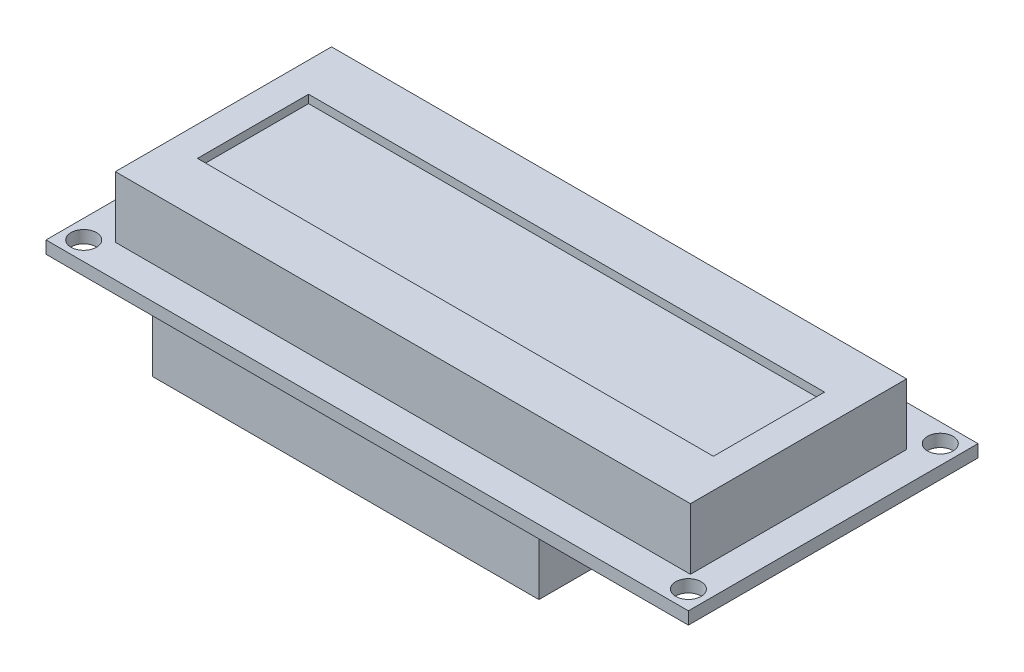
from build123d import *

# Parameters (mm, degrees)
SKETCH1_W           = 80.01
SKETCH1_H           = 36.068
SKETCH1_R           = 1.5875
PCB_DEPTH           = 1.5494
SKETCH2_W           = 71.628
SKETCH2_H           = 26.924
BOSS_EXTRUDE2_DEPTH = 7.62
SKETCH3_W           = 64.262
SKETCH3_H           = 13.843
SCREEN_DEPTH        = 1.016
SKETCH4_W           = 48.133
SKETCH4_H           = 28.6512
CIRCUITS_DEPTH      = 13.462
SKETCH5_W           = 0.635
SKETCH5_H           = 0.635
PINS_DEPTH          = 2.54


with BuildPart() as part:
    # Sketch1 → PCB (new body)
    with BuildSketch(Plane(origin=(0, 0, 0), x_dir=(1, 0, 0), z_dir=(0, 1, 0))):
        with Locations((40.005, 18.034)):
            Rectangle(SKETCH1_W, SKETCH1_H)
        with Locations((2.3495, 2.3495)):
            Circle(SKETCH1_R, mode=Mode.SUBTRACT)
        with Locations((77.6605, 2.3495)):
            Circle(SKETCH1_R, mode=Mode.SUBTRACT)
        with Locations((77.6605, 33.7185)):
            Circle(SKETCH1_R, mode=Mode.SUBTRACT)
        with Locations((2.3495, 33.7185)):
            Circle(SKETCH1_R, mode=Mode.SUBTRACT)
    extrude(amount=PCB_DEPTH)

    # Sketch2 → Boss-Extrude2 (add)
    with BuildSketch(Plane(origin=(0, 1.5494, 0), x_dir=(1, 0, 0), z_dir=(0, 1, 0))):
        with Locations((40.386, 17.526)):
            Rectangle(SKETCH2_W, SKETCH2_H)
    extrude(amount=BOSS_EXTRUDE2_DEPTH)

    # Sketch3 → Screen (cut)
    with BuildSketch(Plane(origin=(0, 9.1694, 0), x_dir=(1, 0, 0), z_dir=(0, 1, 0))):
        with Locations((40.386, 17.526)):
            Rectangle(SKETCH3_W, SKETCH3_H)
    extrude(amount=-SCREEN_DEPTH, mode=Mode.SUBTRACT)

    # Sketch4 → Circuits (add)
    with BuildSketch(Plane.XZ):
        with Locations((30.4165, -21.2344)):
            Rectangle(SKETCH4_W, SKETCH4_H)
    extrude(amount=CIRCUITS_DEPTH)

    # Sketch5 → Pins (add)
    with BuildSketch(Plane.XZ.offset(13.462)):
        with Locations((8.382, -18.6436)):
            Rectangle(SKETCH5_W, SKETCH5_H)
        with Locations((8.382, -21.1836)):
            Rectangle(SKETCH5_W, SKETCH5_H)
        with Locations((8.382, -23.7236)):
            Rectangle(SKETCH5_W, SKETCH5_H)
    extrude(amount=PINS_DEPTH)


solid = part.part
